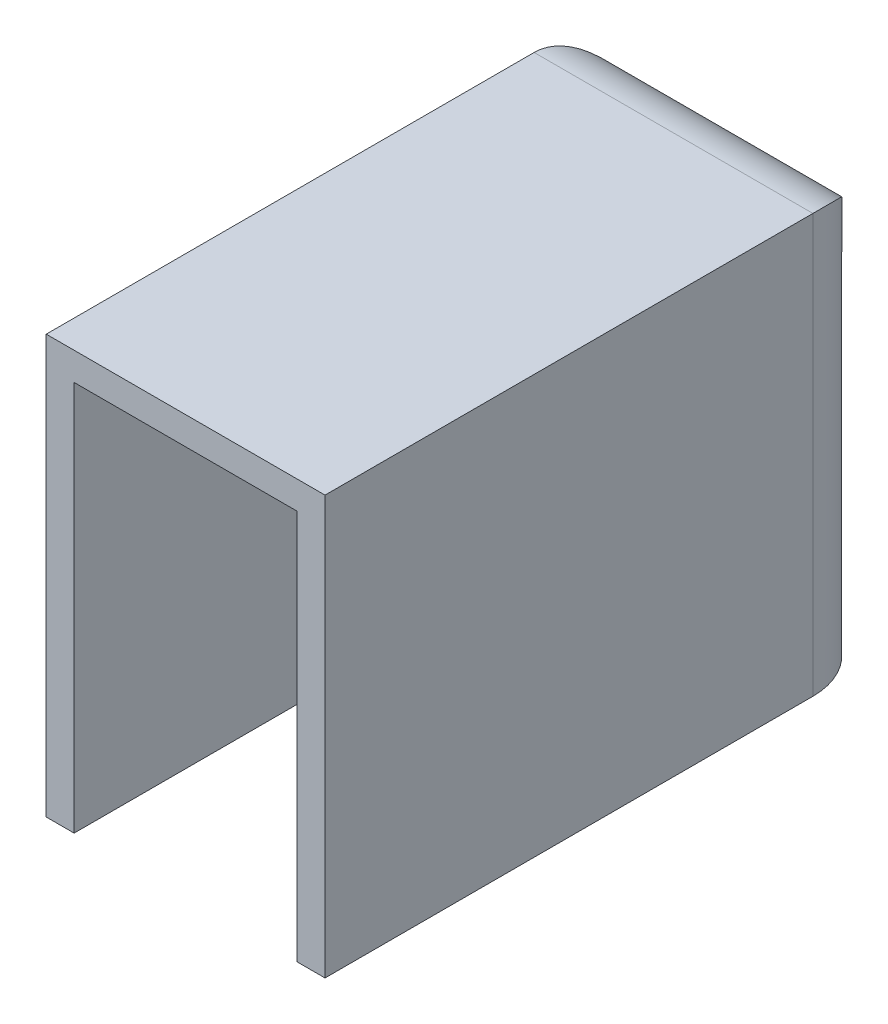
from build123d import *

# Parameters (mm, degrees)
SZKIC1_W                    = 20
SZKIC1_H                    = 30
DODANIE_WYCI_GNI_CIE1_DEPTH = 40
SKORUPA3_T                  = -2
ZAOKR_GLENIE1_R             = 5
SZKIC2_W                    = 12
SZKIC2_H                    = 2
DODANIE_WYCI_GNI_CIE2_DEPTH = 2.5


with BuildPart() as part:
    # Szkic1 → Dodanie-wyciągnięcie1 (new body)
    with BuildSketch(Plane.XY):
        Rectangle(SZKIC1_W, SZKIC1_H)
    extrude(amount=DODANIE_WYCI_GNI_CIE1_DEPTH)

    # Skorupa3
    skorupa3_openings = [part.faces().sort_by_distance(p)[0] for p in [
        (0, 0, 40),
        (0, -15, 20),
    ]]
    offset(amount=SKORUPA3_T, openings=skorupa3_openings, kind=Kind.INTERSECTION)

    # Zaokrąglenie1
    zaokr_glenie1_edges = [part.edges().sort_by_distance(p)[0] for p in [
        (-10, 0, 0),
        (0, 15, 0),
        (10, 0, 0),
    ]]
    fillet(zaokr_glenie1_edges, radius=ZAOKR_GLENIE1_R)

    # Szkic2 → Dodanie-wyciągnięcie2 (add)
    with BuildSketch(Plane.XY.offset(2)):
        with Locations((0, -11)):
            Rectangle(SZKIC2_W, SZKIC2_H)
    extrude(amount=DODANIE_WYCI_GNI_CIE2_DEPTH)


solid = part.part
